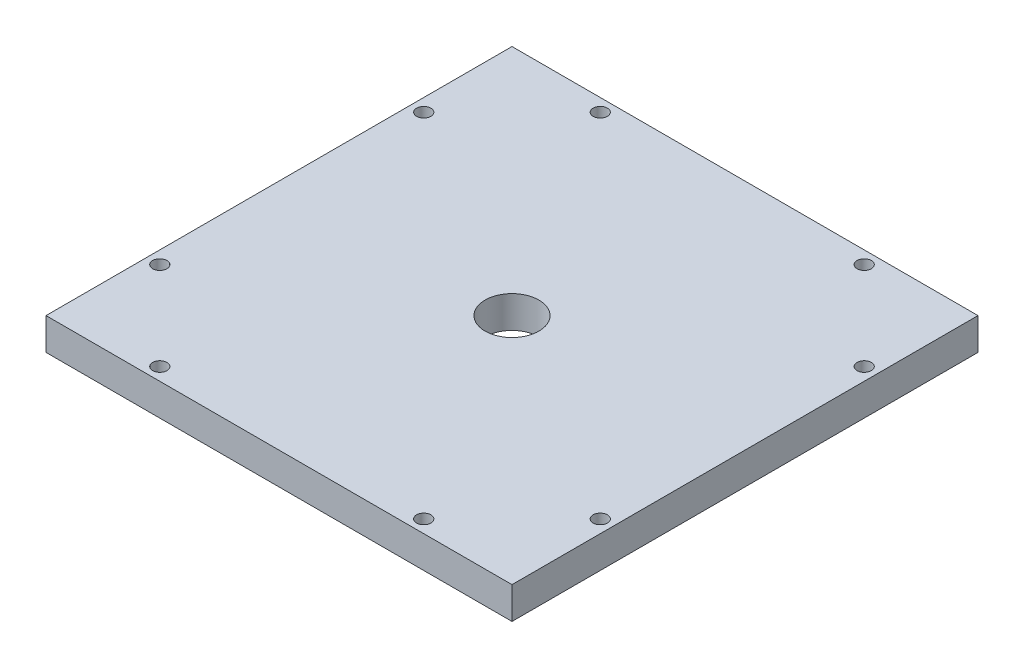
from build123d import *

# Parameters (mm, degrees)
SKETCH1_W           = 92.71
SKETCH1_H           = 92.71
SKETCH1_R           = 5.3578125
BOSS_EXTRUDE1_DEPTH = 6.35
SKETCH2_R           = 1.4224
CUT_EXTRUDE1_DEPTH  = 6.35


with BuildPart() as part:
    # Sketch1 → Boss-Extrude1 (new body)
    with BuildSketch(Plane(origin=(0, 0, 0), x_dir=(1, 0, 0), z_dir=(0, 1, 0))):
        with Locations((46.355, 46.355)):
            Rectangle(SKETCH1_W, SKETCH1_H)
        with Locations((46.355, 46.355)):
            Circle(SKETCH1_R, mode=Mode.SUBTRACT)
    extrude(amount=BOSS_EXTRUDE1_DEPTH)

    # Sketch2 → Cut-Extrude1 (cut)
    with BuildSketch(Plane.XZ):
        with Locations((20.100036, -2.54)):
            Circle(SKETCH2_R)
        with Locations((2.54, -20.100036)):
            Circle(SKETCH2_R)
        with Locations((2.54, -72.609964)):
            Circle(SKETCH2_R)
        with Locations((20.100036, -90.17)):
            Circle(SKETCH2_R)
        with Locations((72.609964, -90.17)):
            Circle(SKETCH2_R)
        with Locations((90.17, -72.609964)):
            Circle(SKETCH2_R)
        with Locations((90.17, -20.100036)):
            Circle(SKETCH2_R)
        with Locations((72.609964, -2.54)):
            Circle(SKETCH2_R)
    extrude(amount=-CUT_EXTRUDE1_DEPTH, mode=Mode.SUBTRACT)


solid = part.part
